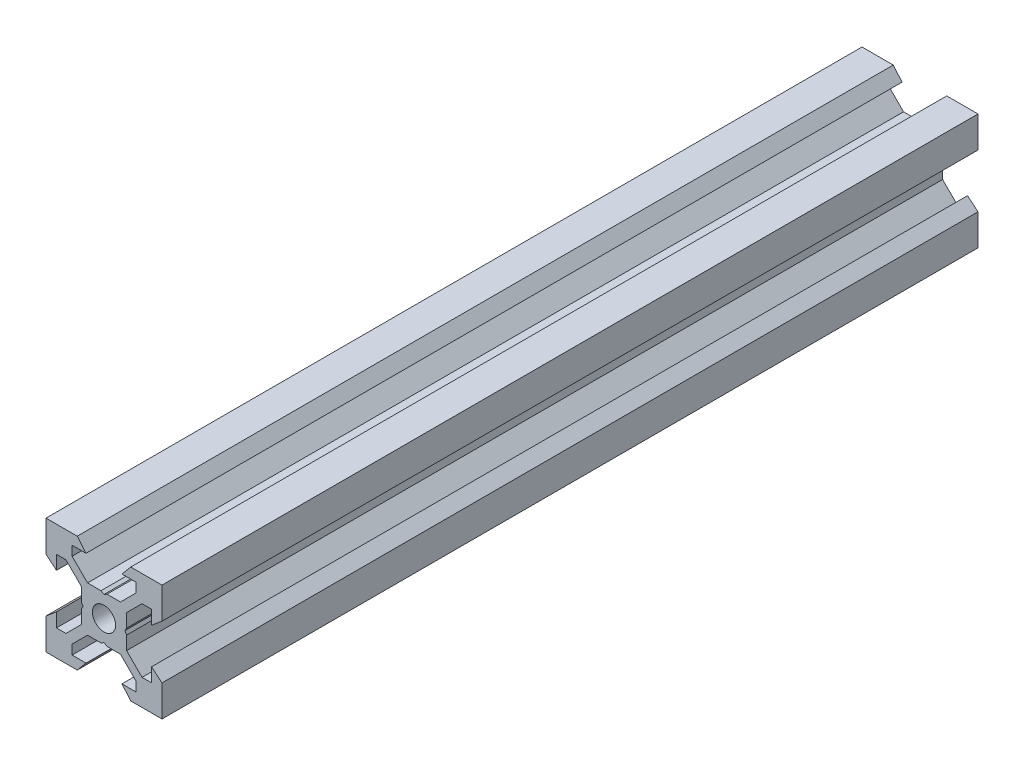
from build123d import *

# Parameters (mm, degrees)
SKETCH1_R           = 2
BOSS_EXTRUDE1_DEPTH = 70.355


with BuildPart() as part:
    # Sketch1 → Boss-Extrude1 (new body, symmetric)
    with BuildSketch(Plane.XY):
        Polygon((10, 10), (10, 4.610379336), (8.2, 3.1), (8.2, 5.5), (6.560660172, 5.5), (3.9, 2.839339828), (3.9, 0.519615242), (3.6, 0), (3.9, -0.519615242), (3.9, -2.839339828), (6.560660172, -5.5), (8.2, -5.5), (8.2, -3.1), (10, -4.610379336), (10, -10), (4.610379336, -10), (3.1, -8.2), (5.5, -8.2), (5.5, -6.560660172), (2.839339828, -3.9), (0.519615242, -3.9), (0, -3.6), (-0.519615242, -3.9), (-2.839339828, -3.9), (-5.5, -6.560660172), (-5.5, -8.2), (-3.1, -8.2), (-4.610379336, -10), (-10, -10), (-10, -4.610379336), (-8.2, -3.1), (-8.2, -5.5), (-6.560660172, -5.5), (-3.9, -2.839339828), (-3.9, -0.519615242), (-3.6, 0), (-3.9, 0.519615242), (-3.9, 2.839339828), (-6.560660172, 5.5), (-8.2, 5.5), (-8.2, 3.1), (-10, 4.610379336), (-10, 10), (-4.610379336, 10), (-3.1, 8.2), (-5.5, 8.2), (-5.5, 6.560660172), (-2.839339828, 3.9), (-0.519615242, 3.9), (0, 3.6), (0.519615242, 3.9), (2.839339828, 3.9), (5.5, 6.560660172), (5.5, 8.2), (3.1, 8.2), (4.610379336, 10), align=None)
        Circle(SKETCH1_R, mode=Mode.SUBTRACT)
    extrude(amount=BOSS_EXTRUDE1_DEPTH, both=True)


solid = part.part
